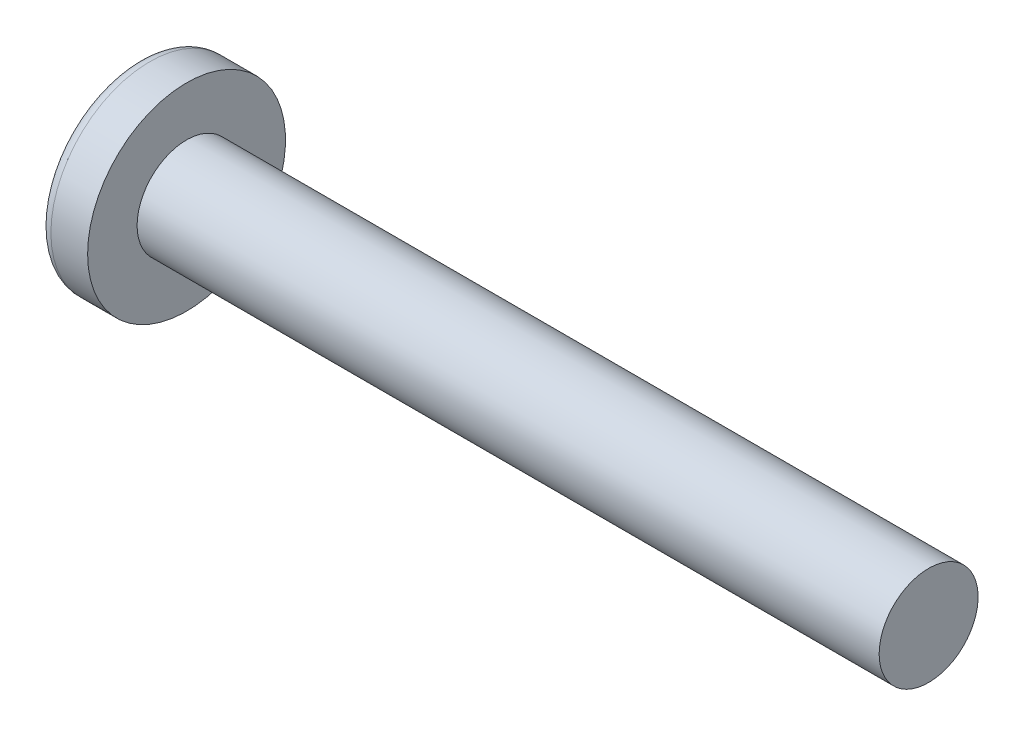
from build123d import *

# Parameters (mm, degrees)
SKETCH3_W         = 0.93
SKETCH3_H         = 4.4
SKETCH4_W         = 0.465
SKETCH4_H         = 0.465
CIRPATTERN1_COUNT = 2
CIRPATTERN1_ANGLE = 90


with BuildPart() as part:
    # BodySke → Base-Revolve (revolve)
    with BuildSketch(Plane.XY):
        with BuildLine():
            Line((3.1, 2), (3.1, 4))
            Line((3.1, 4), (1.616353821, 4))
            ThreePointArc((1.616353821, 4), (1.397629036, 3.947269784), (1.226960106, 3.800664452))
            ThreePointArc((1.226960106, 3.800664452), (0.314340807, 1.996902688), (0, 0))
            Line((0, 0), (33.1, 0))
            Line((33.1, 0), (33.1, 2))
            Line((33.1, 2), (3.1, 2))
        make_face()
    revolve(axis=Axis((-25.4, 0, 0), (1, 0, 0)))

    # Sketch3 → Cut-Loft1 section 0
    with BuildSketch(Plane(origin=(0, 0, 0), x_dir=(0, 0, -1), z_dir=(1, 0, 0))):
        Rectangle(SKETCH3_W, SKETCH3_H)
    # Sketch4 → Cut-Loft1 section 1
    with BuildSketch(Plane(origin=(2.45, 0, 0), x_dir=(0, 0, -1), z_dir=(1, 0, 0))):
        Rectangle(SKETCH4_W, SKETCH4_H)
    cut_loft1 = loft(mode=Mode.SUBTRACT)

    # CirPattern1: Cut-Loft1 ×2 about axis
    cirpattern1_axis = Axis((0, 0, 0), (1, 0, 0))
    for i in range(1, CIRPATTERN1_COUNT):
        add(cut_loft1.rotate(cirpattern1_axis, i * CIRPATTERN1_ANGLE / (CIRPATTERN1_COUNT - 1)), mode=Mode.SUBTRACT)


solid = part.part
